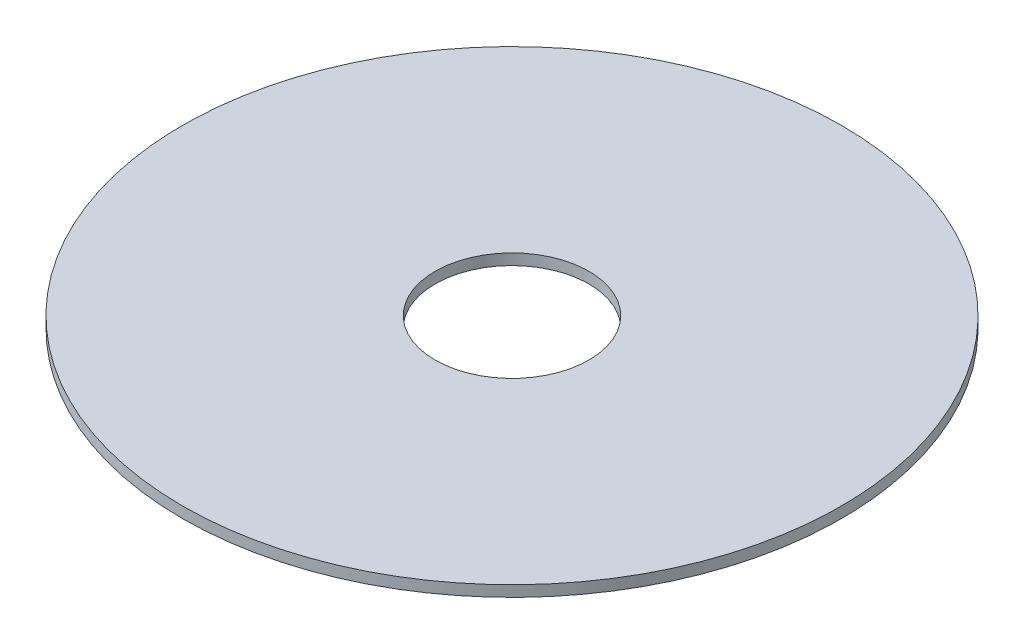
from build123d import *

# Parameters (mm, degrees)
SKETCH1_R           = 15
SKETCH1_R_2         = 3.5
BOSS_EXTRUDE1_DEPTH = 0.5


with BuildPart() as part:
    # Sketch1 → Boss-Extrude1 (new body)
    with BuildSketch(Plane(origin=(0, 0, 0), x_dir=(1, 0, 0), z_dir=(0, 1, 0))):
        Circle(SKETCH1_R)
        Circle(SKETCH1_R_2, mode=Mode.SUBTRACT)
    extrude(amount=BOSS_EXTRUDE1_DEPTH)


solid = part.part
